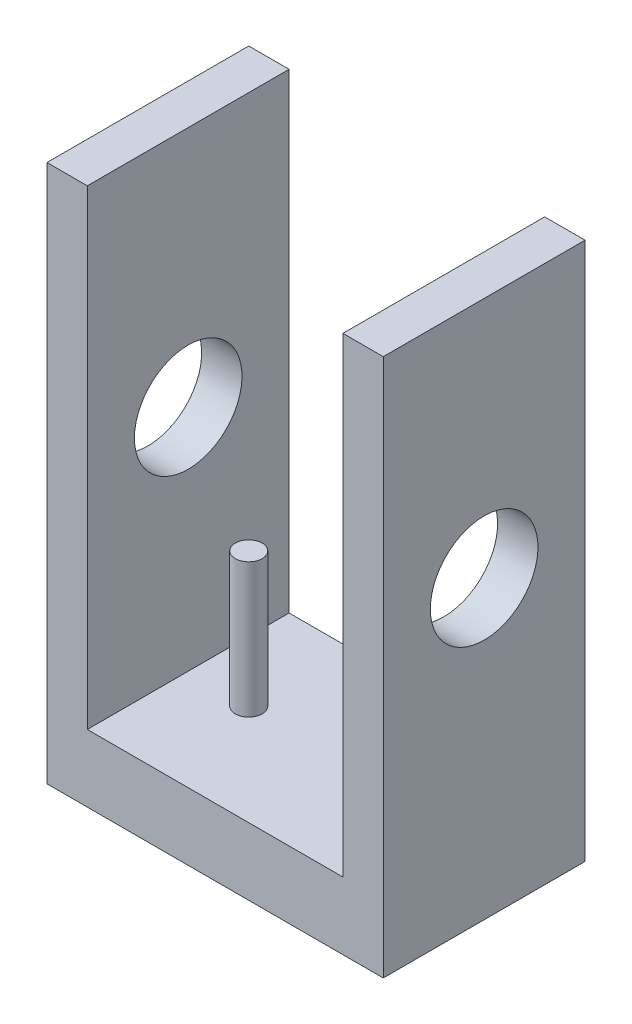
from build123d import *

# Parameters (mm, degrees)
ESQUISSE1_W             = 25
ESQUISSE1_H             = 40
BOSS_EXTRU_2_DEPTH      = 15
ESQUISSE3_W             = 19
ESQUISSE3_H             = 35
ENL_V_MAT_EXTRU_4_DEPTH = 16
ESQUISSE4_R             = 1
BOSS_EXTRU_3_DEPTH      = 10
ESQUISSE5_R             = 4
ENL_V_MAT_EXTRU_5_DEPTH = 26


with BuildPart() as part:
    # Esquisse1 → Boss.-Extru.2 (new body)
    with BuildSketch(Plane.XY):
        with Locations((12.5, -20)):
            Rectangle(ESQUISSE1_W, ESQUISSE1_H)
    extrude(amount=BOSS_EXTRU_2_DEPTH)

    # Esquisse3 → Enlèv. mat.-Extru.4 (cut, through all)
    with BuildSketch(Plane.XY):
        with Locations((12.5, -17.5)):
            Rectangle(ESQUISSE3_W, ESQUISSE3_H)
    extrude(amount=ENL_V_MAT_EXTRU_4_DEPTH, mode=Mode.SUBTRACT)

    # Esquisse4 → Boss.-Extru.3 (add)
    with BuildSketch(Plane(origin=(0, -35, 0), x_dir=(1, 0, 0), z_dir=(0, 1, 0))):
        with Locations((7.5, -7.5)):
            Circle(ESQUISSE4_R)
    extrude(amount=BOSS_EXTRU_3_DEPTH)

    # Esquisse5 → Enlèv. mat.-Extru.5 (cut, through all)
    with BuildSketch(Plane.ZY):
        with Locations((7.5, -18)):
            Circle(ESQUISSE5_R)
    extrude(amount=-ENL_V_MAT_EXTRU_5_DEPTH, mode=Mode.SUBTRACT)


solid = part.part
